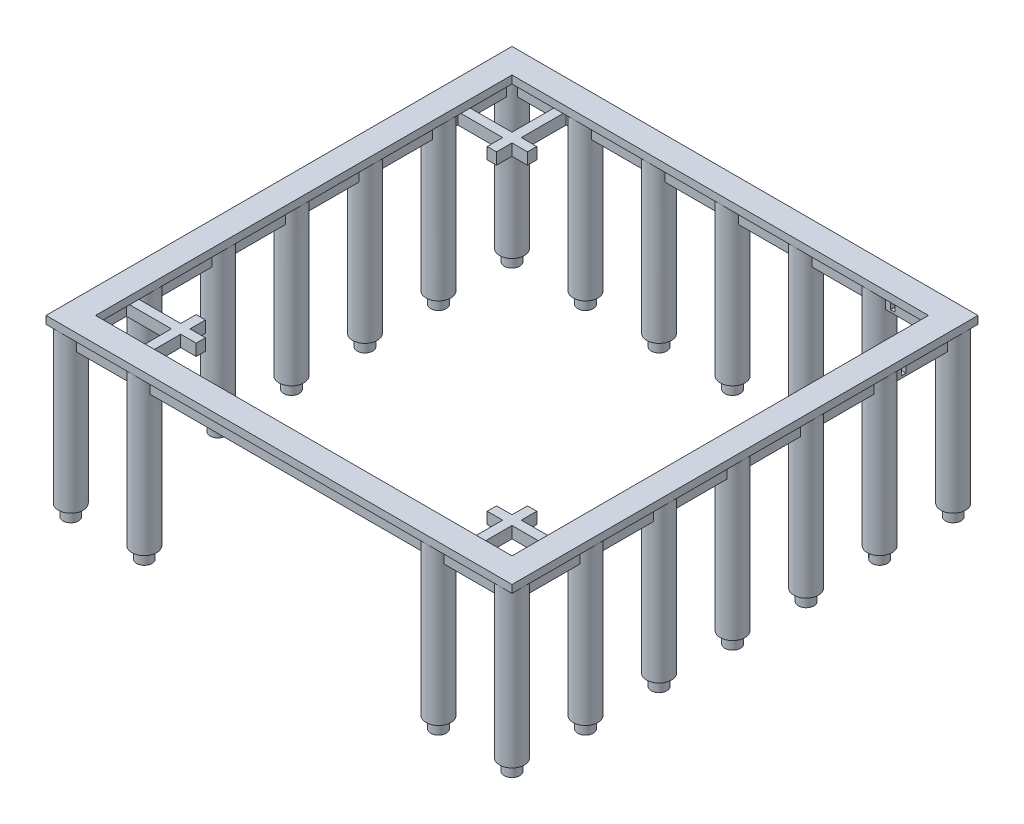
from build123d import *

# Parameters (mm, degrees)
SKETCH_2_R               = 160
EXTRUDE_1_DEPTH          = 2000
EXTRUDE_1_2_DEPTH        = 2000
EXTRUDE_1_3_DEPTH        = 2000
EXTRUDE_1_4_DEPTH        = 2000
EXTRUDE_1_5_DEPTH        = 2000
EXTRUDE_1_6_DEPTH        = 2000
EXTRUDE_1_7_DEPTH        = 2000
EXTRUDE_1_8_DEPTH        = 2000
EXTRUDE_1_9_DEPTH        = 2000
EXTRUDE_1_10_DEPTH       = 2000
EXTRUDE_1_11_DEPTH       = 2000
EXTRUDE_1_12_DEPTH       = 2000
EXTRUDE_1_13_DEPTH       = 2000
EXTRUDE_1_14_DEPTH       = 2000
EXTRUDE_1_15_DEPTH       = 2000
EXTRUDE_1_16_DEPTH       = 2000
EXTRUDE_1_17_DEPTH       = 2000
EXTRUDE_1_18_DEPTH       = 2000
EXTRUDE_1_19_DEPTH       = 2000
EXTRUDE_1_20_DEPTH       = 2000
EXTRUDE_1_21_DEPTH       = 2000
SKETCH_4_W               = 6020
SKETCH_4_H               = 6020
SKETCH_4_R               = 160
SKETCH_4_W_2             = 5700
SKETCH_4_H_2             = 5700
SKETCH_4_W_3             = 5380
SKETCH_4_H_3             = 5380
EXTRUDE_2_DEPTH          = 100
SKETCH_5_W               = 70
SKETCH_5_H               = 200
EXTRUDE_3_DEPTH          = 5700
MIRROR_4_COPY_1_SKETCH_W = 70
MIRROR_4_COPY_1_SKETCH_H = 200
MIRROR_4_COPY_1_DEPTH    = 5700
SKETCH_9_R               = 100
EXTRUDE_4_DEPTH          = 150
EXTRUDE_START            = -150
SKETCH_11_W              = 160
SKETCH_11_H              = 120
SKETCH_11_W_2            = 490
SKETCH_11_W_3            = 120
SKETCH_11_W_4            = 80
SKETCH_11_H_2            = 80
SKETCH_11_H_3            = 490
SKETCH_11_H_4            = 160.112427504
EXTRUDE_5_DEPTH          = 150
SKETCH_12_W              = 60
SKETCH_12_H              = 90
CUT_EXTRUDE_1_DEPTH      = 4891
SKETCH_13_W              = 60
SKETCH_13_H              = 90
CUT_EXTRUDE_2_DEPTH      = 4891


with BuildPart() as part:
    # 草图2 → 凸台-拉伸1 (new body)
    with BuildSketch(Plane(origin=(0, 0, 0), x_dir=(1, 0, 0), z_dir=(0, 1, 0))):
        with Locations((450, 450)):
            Circle(SKETCH_2_R)
    extrude(amount=EXTRUDE_1_DEPTH)



with BuildPart() as body_2:
    # 草图2 → Extrude 1 2 (new body)
    with BuildSketch(Plane(origin=(0, 0, 0), x_dir=(1, 0, 0), z_dir=(0, 1, 0))):
        with Locations((6150, 450)):
            Circle(SKETCH_2_R)
    extrude(amount=EXTRUDE_1_2_DEPTH)


with BuildPart() as body_3:
    # 草图2 → Extrude 1 3 (new body)
    with BuildSketch(Plane(origin=(0, 0, 0), x_dir=(1, 0, 0), z_dir=(0, 1, 0))):
        with Locations((6150, 6150)):
            Circle(SKETCH_2_R)
    extrude(amount=EXTRUDE_1_3_DEPTH)


with BuildPart() as body_4:
    # 草图2 → Extrude 1 4 (new body)
    with BuildSketch(Plane(origin=(0, 0, 0), x_dir=(1, 0, 0), z_dir=(0, 1, 0))):
        with Locations((450, 6150)):
            Circle(SKETCH_2_R)
    extrude(amount=EXTRUDE_1_4_DEPTH)


with BuildPart() as body_5:
    # 草图2 → Extrude 1 5 (new body)
    with BuildSketch(Plane(origin=(0, 0, 0), x_dir=(1, 0, 0), z_dir=(0, 1, 0))):
        with Locations((450, 5200)):
            Circle(SKETCH_2_R)
    extrude(amount=EXTRUDE_1_5_DEPTH)


with BuildPart() as body_6:
    # 草图2 → Extrude 1 6 (new body)
    with BuildSketch(Plane(origin=(0, 0, 0), x_dir=(1, 0, 0), z_dir=(0, 1, 0))):
        with Locations((6150, 5200)):
            Circle(SKETCH_2_R)
    extrude(amount=EXTRUDE_1_6_DEPTH)


with BuildPart() as body_7:
    # 草图2 → Extrude 1 7 (new body)
    with BuildSketch(Plane(origin=(0, 0, 0), x_dir=(1, 0, 0), z_dir=(0, 1, 0))):
        with Locations((450, 4250)):
            Circle(SKETCH_2_R)
    extrude(amount=EXTRUDE_1_7_DEPTH)


with BuildPart() as body_8:
    # 草图2 → Extrude 1 8 (new body)
    with BuildSketch(Plane(origin=(0, 0, 0), x_dir=(1, 0, 0), z_dir=(0, 1, 0))):
        with Locations((6150, 4250)):
            Circle(SKETCH_2_R)
    extrude(amount=EXTRUDE_1_8_DEPTH)


with BuildPart() as body_9:
    # 草图2 → Extrude 1 9 (new body)
    with BuildSketch(Plane(origin=(0, 0, 0), x_dir=(1, 0, 0), z_dir=(0, 1, 0))):
        with Locations((450, 3300)):
            Circle(SKETCH_2_R)
    extrude(amount=EXTRUDE_1_9_DEPTH)


with BuildPart() as body_10:
    # 草图2 → Extrude 1 10 (new body)
    with BuildSketch(Plane(origin=(0, 0, 0), x_dir=(1, 0, 0), z_dir=(0, 1, 0))):
        with Locations((6150, 3300)):
            Circle(SKETCH_2_R)
    extrude(amount=EXTRUDE_1_10_DEPTH)


with BuildPart() as body_11:
    # 草图2 → Extrude 1 11 (new body)
    with BuildSketch(Plane(origin=(0, 0, 0), x_dir=(1, 0, 0), z_dir=(0, 1, 0))):
        with Locations((450, 2350)):
            Circle(SKETCH_2_R)
    extrude(amount=EXTRUDE_1_11_DEPTH)


with BuildPart() as body_12:
    # 草图2 → Extrude 1 12 (new body)
    with BuildSketch(Plane(origin=(0, 0, 0), x_dir=(1, 0, 0), z_dir=(0, 1, 0))):
        with Locations((6150, 2350)):
            Circle(SKETCH_2_R)
    extrude(amount=EXTRUDE_1_12_DEPTH)


with BuildPart() as body_13:
    # 草图2 → Extrude 1 13 (new body)
    with BuildSketch(Plane(origin=(0, 0, 0), x_dir=(1, 0, 0), z_dir=(0, 1, 0))):
        with Locations((450, 1400)):
            Circle(SKETCH_2_R)
    extrude(amount=EXTRUDE_1_13_DEPTH)


with BuildPart() as body_14:
    # 草图2 → Extrude 1 14 (new body)
    with BuildSketch(Plane(origin=(0, 0, 0), x_dir=(1, 0, 0), z_dir=(0, 1, 0))):
        with Locations((6150, 1400)):
            Circle(SKETCH_2_R)
    extrude(amount=EXTRUDE_1_14_DEPTH)


with BuildPart() as body_15:
    # 草图2 → Extrude 1 15 (new body)
    with BuildSketch(Plane(origin=(0, 0, 0), x_dir=(1, 0, 0), z_dir=(0, 1, 0))):
        with Locations((1400, 6150)):
            Circle(SKETCH_2_R)
    extrude(amount=EXTRUDE_1_15_DEPTH)


with BuildPart() as body_16:
    # 草图2 → Extrude 1 16 (new body)
    with BuildSketch(Plane(origin=(0, 0, 0), x_dir=(1, 0, 0), z_dir=(0, 1, 0))):
        with Locations((1400, 450)):
            Circle(SKETCH_2_R)
    extrude(amount=EXTRUDE_1_16_DEPTH)


with BuildPart() as body_17:
    # 草图2 → Extrude 1 17 (new body)
    with BuildSketch(Plane(origin=(0, 0, 0), x_dir=(1, 0, 0), z_dir=(0, 1, 0))):
        with Locations((2350, 6150)):
            Circle(SKETCH_2_R)
    extrude(amount=EXTRUDE_1_17_DEPTH)


with BuildPart() as body_18:
    # 草图2 → Extrude 1 18 (new body)
    with BuildSketch(Plane(origin=(0, 0, 0), x_dir=(1, 0, 0), z_dir=(0, 1, 0))):
        with Locations((3300, 6150)):
            Circle(SKETCH_2_R)
    extrude(amount=EXTRUDE_1_18_DEPTH)


with BuildPart() as body_19:
    # 草图2 → Extrude 1 19 (new body)
    with BuildSketch(Plane(origin=(0, 0, 0), x_dir=(1, 0, 0), z_dir=(0, 1, 0))):
        with Locations((4250, 6150)):
            Circle(SKETCH_2_R)
    extrude(amount=EXTRUDE_1_19_DEPTH)


with BuildPart() as body_20:
    # 草图2 → Extrude 1 20 (new body)
    with BuildSketch(Plane(origin=(0, 0, 0), x_dir=(1, 0, 0), z_dir=(0, 1, 0))):
        with Locations((5200, 6150)):
            Circle(SKETCH_2_R)
    extrude(amount=EXTRUDE_1_20_DEPTH)


with BuildPart() as body_21:
    # 草图2 → Extrude 1 21 (new body)
    with BuildSketch(Plane(origin=(0, 0, 0), x_dir=(1, 0, 0), z_dir=(0, 1, 0))):
        with Locations((5200, 450)):
            Circle(SKETCH_2_R)
    extrude(amount=EXTRUDE_1_21_DEPTH)


with BuildPart() as part_1:
    add(part.part)

    add(body_2.part)  # 凸台-拉伸2 merges body 2

    add(body_3.part)  # 凸台-拉伸2 merges body 3

    add(body_4.part)  # 凸台-拉伸2 merges body 4

    add(body_5.part)  # 凸台-拉伸2 merges body 5

    add(body_6.part)  # 凸台-拉伸2 merges body 6

    add(body_7.part)  # 凸台-拉伸2 merges body 7

    add(body_8.part)  # 凸台-拉伸2 merges body 8

    add(body_9.part)  # 凸台-拉伸2 merges body 9

    add(body_10.part)  # 凸台-拉伸2 merges body 10

    add(body_11.part)  # 凸台-拉伸2 merges body 11

    add(body_12.part)  # 凸台-拉伸2 merges body 12

    add(body_13.part)  # 凸台-拉伸2 merges body 13

    add(body_14.part)  # 凸台-拉伸2 merges body 14

    add(body_15.part)  # 凸台-拉伸2 merges body 15

    add(body_16.part)  # 凸台-拉伸2 merges body 16

    add(body_17.part)  # 凸台-拉伸2 merges body 17

    add(body_18.part)  # 凸台-拉伸2 merges body 18

    add(body_19.part)  # 凸台-拉伸2 merges body 19

    add(body_20.part)  # 凸台-拉伸2 merges body 20

    add(body_21.part)  # 凸台-拉伸2 merges body 21
    # 草图4 → 凸台-拉伸2 (add)
    with BuildSketch(Plane(origin=(0, 2000, 0), x_dir=(1, 0, 0), z_dir=(0, 1, 0))):
        with Locations((3300, 3300)):
            Rectangle(SKETCH_4_W, SKETCH_4_H)
        with Locations((450, 6150)):
            Circle(SKETCH_4_R, mode=Mode.SUBTRACT)
        with Locations((3300, 3300)):
            Rectangle(SKETCH_4_W_2, SKETCH_4_H_2, mode=Mode.SUBTRACT)
        with Locations((450, 6150)):
            Circle(SKETCH_4_R)
        with Locations((3300, 3300)):
            Rectangle(SKETCH_4_W_2, SKETCH_4_H_2)
        with Locations((3300, 3300)):
            Rectangle(SKETCH_4_W_3, SKETCH_4_H_3, mode=Mode.SUBTRACT)
        with BuildLine():
            ThreePointArc((450, 6310), (336.86291501, 6263.13708499), (290, 6150))
            ThreePointArc((290, 6150), (336.86291501, 6036.86291501), (450, 5990))
            Line((450, 5990), (450, 6150))
            Line((450, 6150), (610, 6150))
            ThreePointArc((610, 6150), (563.13708499, 6263.13708499), (450, 6310))
        make_face()
        with BuildLine():
            Line((450, 6150), (450, 5990))
            ThreePointArc((450, 5990), (563.13708499, 6036.86291501), (610, 6150))
            Line((610, 6150), (450, 6150))
        make_face()
        with BuildLine():
            Line((450, 6310), (290, 6310))
            Line((290, 6310), (290, 6150))
            ThreePointArc((290, 6150), (336.86291501, 6263.13708499), (450, 6310))
        make_face()
    extrude(amount=EXTRUDE_2_DEPTH)

    # 草图5 → 凸台-拉伸3 (add)
    with BuildSketch(Plane.XY.offset(-450)):
        with Locations((6185, 1900)):
            Rectangle(SKETCH_5_W, SKETCH_5_H)
        with Locations((6115, 1900)):
            Rectangle(SKETCH_5_W, SKETCH_5_H)
    extrude_3 = extrude(amount=-EXTRUDE_3_DEPTH)

    # 镜向3: 凸台-拉伸3 across plane
    add(extrude_3.mirror(Plane(origin=(3300, 0, 0), x_dir=(0, 0, 1), z_dir=(1, 0, 0))))

    # 镜向4: 凸台-拉伸3 across plane
    add(extrude_3.mirror(Plane(origin=(0, 0, 0), x_dir=(-0.707106781, 0, 0.707106781), z_dir=(-0.707106781, 0, -0.707106781))))

    # 镜向4 copy 1 sketch → 镜向4 copy 1 (add)
    with BuildSketch(Plane(origin=(450, 0, -6600), x_dir=(0, 0, 1), z_dir=(-1, 0, 0))):
        with Locations((6185, 1900)):
            Rectangle(MIRROR_4_COPY_1_SKETCH_W, MIRROR_4_COPY_1_SKETCH_H)
        with Locations((6115, 1900)):
            Rectangle(MIRROR_4_COPY_1_SKETCH_W, MIRROR_4_COPY_1_SKETCH_H)
    extrude(amount=-MIRROR_4_COPY_1_DEPTH)

    # 草图9 → 凸台-拉伸4 (add)
    with BuildSketch(Plane.XZ):
        with Locations((6150, -6150)):
            Circle(SKETCH_9_R)
        with Locations((5200, -6150)):
            Circle(SKETCH_9_R)
        with Locations((4250, -6150)):
            Circle(SKETCH_9_R)
        with Locations((3300, -6150)):
            Circle(SKETCH_9_R)
        with Locations((2350, -6150)):
            Circle(SKETCH_9_R)
        with Locations((1400, -6150)):
            Circle(SKETCH_9_R)
        with Locations((450, -6150)):
            Circle(SKETCH_9_R)
        with Locations((6150, -5200)):
            Circle(SKETCH_9_R)
        with Locations((6150, -4250)):
            Circle(SKETCH_9_R)
        with Locations((6150, -3300)):
            Circle(SKETCH_9_R)
        with Locations((6150, -2350)):
            Circle(SKETCH_9_R)
        with Locations((6150, -1400)):
            Circle(SKETCH_9_R)
        with Locations((6150, -450)):
            Circle(SKETCH_9_R)
        with Locations((5200, -450)):
            Circle(SKETCH_9_R)
        with Locations((1400, -450)):
            Circle(SKETCH_9_R)
        with Locations((450, -450)):
            Circle(SKETCH_9_R)
        with Locations((450, -5200)):
            Circle(SKETCH_9_R)
        with Locations((450, -4250)):
            Circle(SKETCH_9_R)
        with Locations((450, -3300)):
            Circle(SKETCH_9_R)
        with Locations((450, -2350)):
            Circle(SKETCH_9_R)
        with Locations((450, -1400)):
            Circle(SKETCH_9_R)
    extrude(amount=EXTRUDE_4_DEPTH)

    # 草图11 → 凸台-拉伸5 (add)
    with BuildSketch(Plane(origin=(0, 2100, 0), x_dir=(1, 0, 0), z_dir=(0, 1, 0)).offset(EXTRUDE_START)):
        with Locations((530, 1160)):
            Rectangle(SKETCH_11_W, SKETCH_11_H)
        with Locations((855, 1160)):
            Rectangle(SKETCH_11_W_2, SKETCH_11_H)
        with Locations((1160, 1160)):
            Rectangle(SKETCH_11_W_3, SKETCH_11_H)
        with Locations((1260, 1160)):
            Rectangle(SKETCH_11_W_4, SKETCH_11_H)
        with Locations((1360, 1160)):
            Rectangle(SKETCH_11_W_3, SKETCH_11_H)
        with Locations((1160, 1260)):
            Rectangle(SKETCH_11_W_3, SKETCH_11_H_2)
        with Locations((1160, 1360)):
            Rectangle(SKETCH_11_W_3, SKETCH_11_H)
        with Locations((1160, 855)):
            Rectangle(SKETCH_11_W_3, SKETCH_11_H_3)
        with Locations((1160, 529.943786248)):
            Rectangle(SKETCH_11_W_3, SKETCH_11_H_4)
    extrude_5 = extrude(amount=-EXTRUDE_5_DEPTH)

    # 镜向5: 凸台-拉伸5 across plane
    add(extrude_5.mirror(Plane.XY.offset(-3300)))

    # 镜向6: 凸台-拉伸5 across plane
    add(extrude_5.mirror(Plane(origin=(3300, 0, 0), x_dir=(0, 0, 1), z_dir=(1, 0, 0))))

    # 草图12 → 切除-拉伸1 (cut, through all)
    with BuildSketch(Plane(origin=(0, 0, -1420), x_dir=(-1, 0, 0), z_dir=(0, 0, -1))):
        with Locations((-5440, 1875)):
            Rectangle(SKETCH_12_W, SKETCH_12_H)
    extrude(amount=CUT_EXTRUDE_1_DEPTH, mode=Mode.SUBTRACT)

    # 草图13 → 切除-拉伸2 (cut, through all)
    with BuildSketch(Plane(origin=(1420, 0, 0), x_dir=(0, 0, -1), z_dir=(1, 0, 0))):
        with Locations((5440, 1875)):
            Rectangle(SKETCH_13_W, SKETCH_13_H)
    extrude(amount=CUT_EXTRUDE_2_DEPTH, mode=Mode.SUBTRACT)


solid = part_1.part
